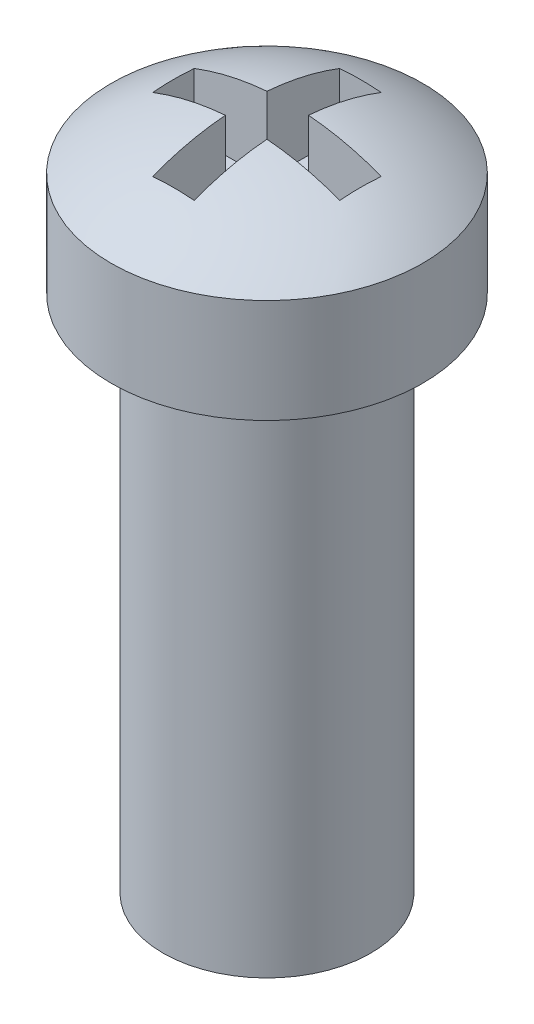
from build123d import *

# Parameters (mm, degrees)
SKETCH1_R           = 1
BOSS_EXTRUDE1_DEPTH = 5
SKETCH2_R           = 1.5
BOSS_EXTRUDE2_DEPTH = 1
DOME1_FACE_RADIUS   = 1.5
DOME1_HEIGHT        = 0.5
SKETCH3_W           = 0.7
SKETCH3_H           = 0.4
SKETCH3_W_2         = 0.4
SKETCH3_H_2         = 0.7
CUT_EXTRUDE1_DEPTH  = 0.75


with BuildPart() as part:
    # Sketch1 → Boss-Extrude1 (new body)
    with BuildSketch(Plane(origin=(0, 0, 0), x_dir=(1, 0, 0), z_dir=(0, 1, 0))):
        Circle(SKETCH1_R)
    extrude(amount=BOSS_EXTRUDE1_DEPTH)

    # Sketch2 → Boss-Extrude2 (add)
    with BuildSketch(Plane(origin=(0, 5, 0), x_dir=(1, 0, 0), z_dir=(0, 1, 0))):
        Circle(SKETCH2_R)
    extrude(amount=BOSS_EXTRUDE2_DEPTH)

    # Dome1: a dome of height H over a round flat face of radius A is a cap of a sphere of radius (A * A + H * H) / (2 * H)
    dome1_r = (DOME1_FACE_RADIUS * DOME1_FACE_RADIUS + DOME1_HEIGHT * DOME1_HEIGHT) / (2 * DOME1_HEIGHT)
    dome1_base = Plane((0, 6, 0), z_dir=(0, 1, 0))
    with Locations(dome1_base.offset(DOME1_HEIGHT - dome1_r)):
        dome1_ball = Sphere(dome1_r, mode=Mode.PRIVATE)
    add(split(dome1_ball, bisect_by=dome1_base, keep=Keep.TOP, mode=Mode.PRIVATE))

    # Sketch3 → Cut-Extrude1 (cut)
    with BuildSketch(Plane(origin=(0, 6.5, 0), x_dir=(1, 0, 0), z_dir=(0, 1, 0))):
        with Locations((-0.55, 0)):
            Rectangle(SKETCH3_W, SKETCH3_H)
        Rectangle(SKETCH3_W_2, SKETCH3_H)
        with Locations((0, 0.55)):
            Rectangle(SKETCH3_W_2, SKETCH3_H_2)
        with Locations((0.55, 0)):
            Rectangle(SKETCH3_W, SKETCH3_H)
        with Locations((0, -0.55)):
            Rectangle(SKETCH3_W_2, SKETCH3_H_2)
    extrude(amount=-CUT_EXTRUDE1_DEPTH, mode=Mode.SUBTRACT)


solid = part.part
